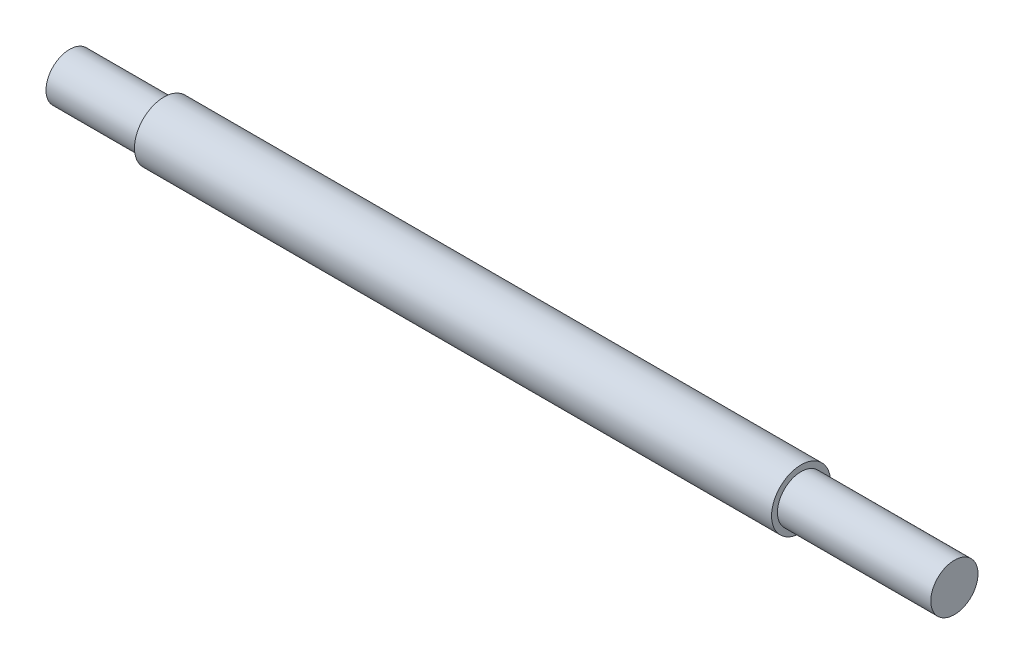
from build123d import *

# Parameters (mm, degrees)
SKETCH1_R           = 2.5
BOSS_EXTRUDE1_DEPTH = 35
SKETCH2_R           = 2.5
SKETCH2_R_2         = 2
CUT_EXTRUDE1_DEPTH  = 8
SKETCH3_R           = 2.5
SKETCH3_R_2         = 2
CUT_EXTRUDE2_DEPTH  = 8
SKETCH4_R           = 2
BOSS_EXTRUDE2_DEPTH = 5


with BuildPart() as part:
    # Sketch1 → Boss-Extrude1 (new body, symmetric)
    with BuildSketch(Plane(origin=(0, 0, 0), x_dir=(0, 0, -1), z_dir=(1, 0, 0))):
        Circle(SKETCH1_R)
    extrude(amount=BOSS_EXTRUDE1_DEPTH, both=True)

    # Sketch2 → Cut-Extrude1 (cut)
    with BuildSketch(Plane(origin=(35, 0, 0), x_dir=(0, 0, -1), z_dir=(1, 0, 0))):
        Circle(SKETCH2_R)
        Circle(SKETCH2_R_2, mode=Mode.SUBTRACT)
    extrude(amount=-CUT_EXTRUDE1_DEPTH, mode=Mode.SUBTRACT)

    # Sketch3 → Cut-Extrude2 (cut)
    with BuildSketch(Plane.ZY.offset(35)):
        Circle(SKETCH3_R)
        Circle(SKETCH3_R_2, mode=Mode.SUBTRACT)
    extrude(amount=-CUT_EXTRUDE2_DEPTH, mode=Mode.SUBTRACT)

    # Sketch4 → Boss-Extrude2 (add)
    with BuildSketch(Plane(origin=(35, 0, 0), x_dir=(0, 0, -1), z_dir=(1, 0, 0))):
        Circle(SKETCH4_R)
    extrude(amount=BOSS_EXTRUDE2_DEPTH)


solid = part.part
